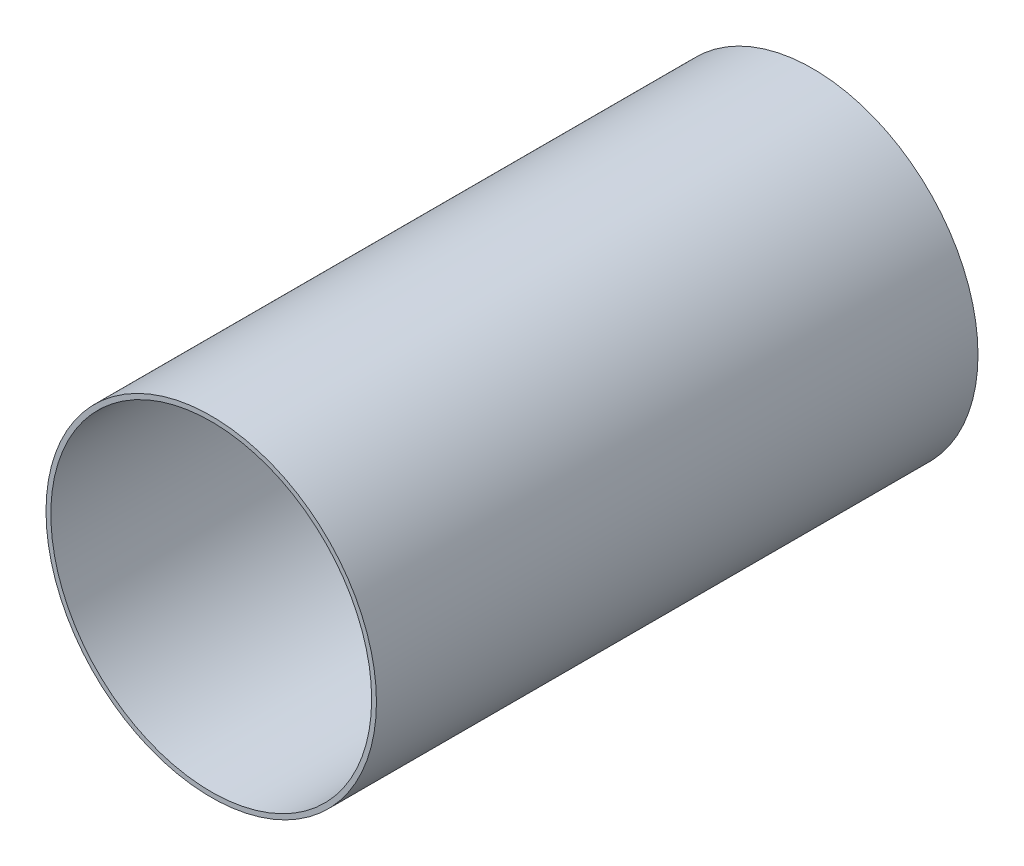
from build123d import *

# Parameters (mm, degrees)
ESQUISSE1_R        = 41.2
ESQUISSE1_R_2      = 40
BOSS_EXTRU_1_DEPTH = 150


with BuildPart() as part:
    # Esquisse1 → Boss.-Extru.1 (new body)
    with BuildSketch(Plane.XY):
        Circle(ESQUISSE1_R)
        Circle(ESQUISSE1_R_2, mode=Mode.SUBTRACT)
    extrude(amount=BOSS_EXTRU_1_DEPTH)


solid = part.part
